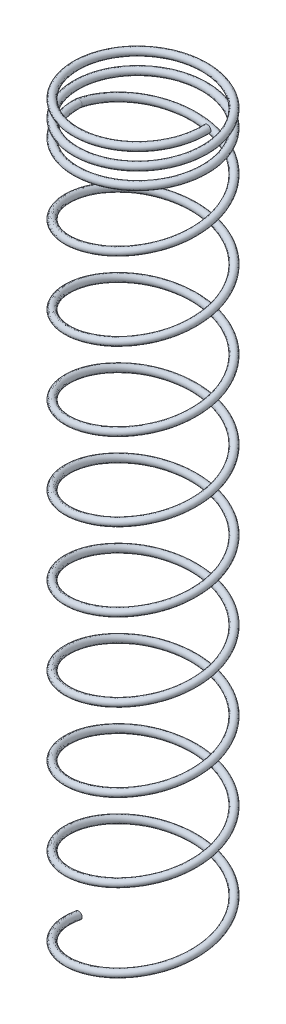
from build123d import *

# Parameters (mm, degrees)
SWEEP1_PITCH       = 2.777066667
SWEEP1_HEIGHT      = 24.9936
SWEEP1_RADIUS      = 2.5019
SWEEP1_START_ANGLE = -90
SKETCH2_R          = 0.127
SWEEP2_PITCH       = 0.600456
SWEEP2_HEIGHT      = 1.50114
SWEEP2_RADIUS      = 2.5019
SWEEP2_START_ANGLE = -90
SKETCH5_R          = 0.127


with BuildPart() as part:
    # Sweep1: sweep along a helix
    with BuildLine() as sweep1_path:
        add(Helix(SWEEP1_PITCH, SWEEP1_HEIGHT, SWEEP1_RADIUS, center=(0, 0, 0), direction=(0, 1, 0), mode=Mode.PRIVATE).rotate(Axis((0, 0, 0), (0, 1, 0)), SWEEP1_START_ANGLE))
    # Sketch2 → Sweep1 (sweep)
    with BuildSketch(Plane.XY):
        with Locations((-2.287175902, 0.184465964)):
            Circle(SKETCH2_R)
    sweep(path=sweep1_path.line, is_frenet=True)

    # Sweep2: sweep along a helix
    with BuildLine() as sweep2_path:
        add(Helix(SWEEP2_PITCH, SWEEP2_HEIGHT, SWEEP2_RADIUS, center=(0, 24.92756, 0), direction=(0, 1, 0), mode=Mode.PRIVATE).rotate(Axis((0, 24.92756, 0), (0, 1, 0)), SWEEP2_START_ANGLE))
    # Sketch5 → Sweep2 (sweep)
    with BuildSketch(Plane.XY):
        with Locations((-2.287175902, 25.178065964)):
            Circle(SKETCH5_R)
    sweep(path=sweep2_path.line, is_frenet=True)


solid = part.part
